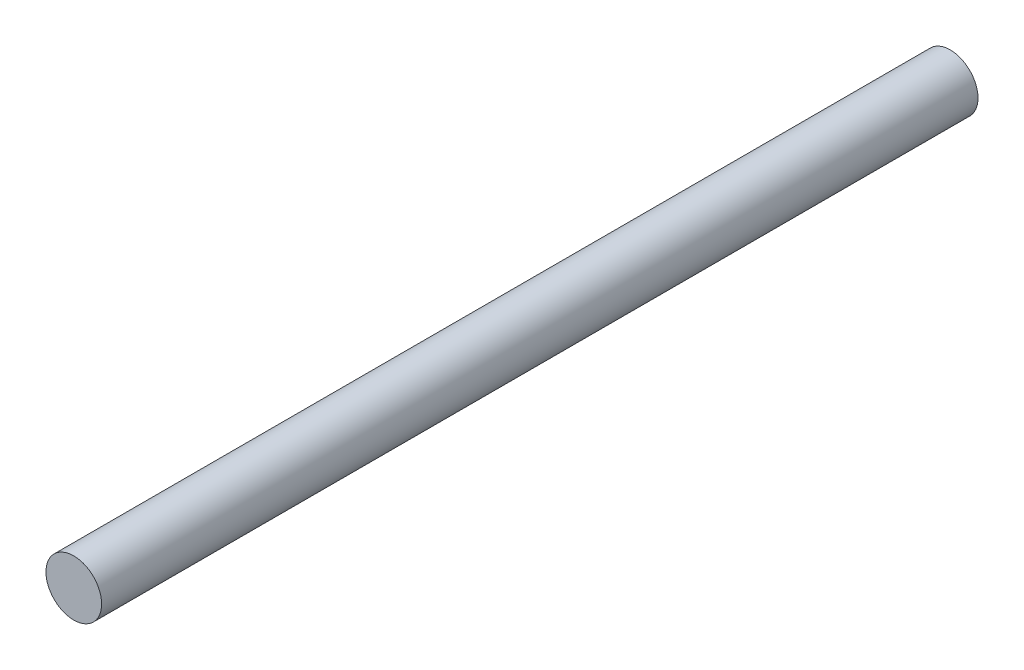
from build123d import *

# Parameters (mm, degrees)
SKETCH1_R           = 6.35
BOSS_EXTRUDE1_DEPTH = 200


with BuildPart() as part:
    # Sketch1 → Boss-Extrude1 (new body)
    with BuildSketch(Plane.XY):
        Circle(SKETCH1_R)
    extrude(amount=BOSS_EXTRUDE1_DEPTH)


solid = part.part
